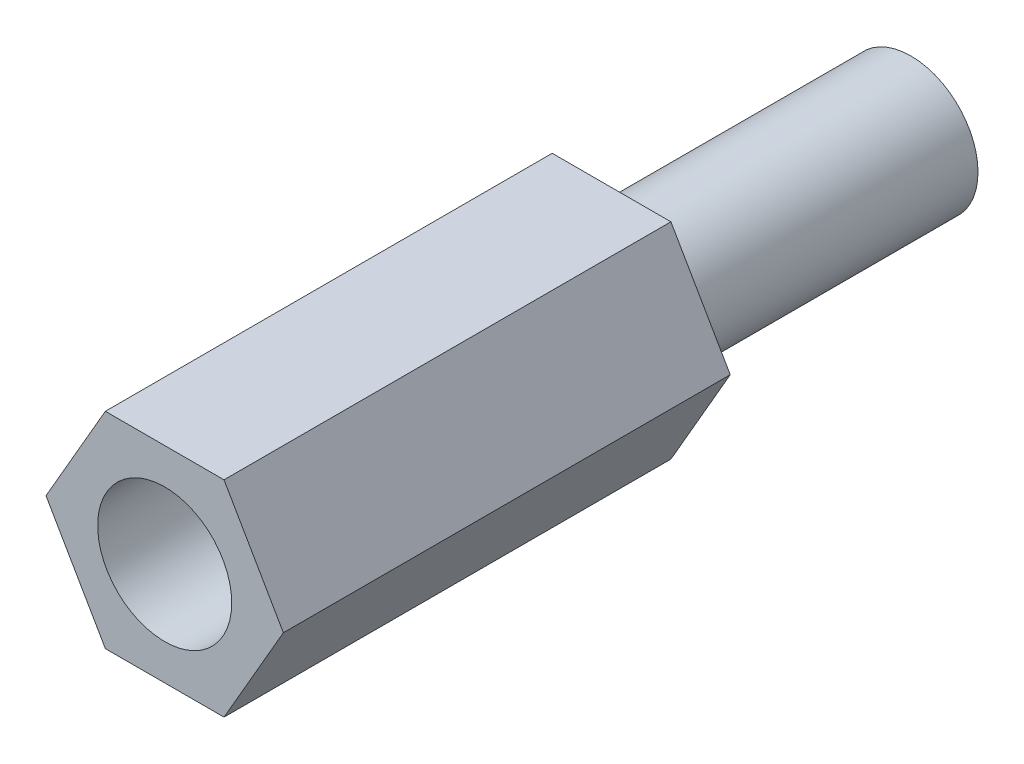
from build123d import *

# Parameters (mm, degrees)
SALIENTE_EXTRUIR1_DEPTH = 10
CROQUIS2_R              = 1.5
SALIENTE_EXTRUIR2_DEPTH = 6.7
CROQUIS3_R              = 1.5
CORTAR_EXTRUIR1_DEPTH   = 7


with BuildPart() as part:
    # Croquis1 → Saliente-Extruir1 (new body)
    with BuildSketch(Plane.XY):
        Polygon((2.655811238, 0), (1.327905619, 2.3), (-1.327905619, 2.3), (-2.655811238, 0), (-1.327905619, -2.3), (1.327905619, -2.3), align=None)
    extrude(amount=SALIENTE_EXTRUIR1_DEPTH)

    # Croquis2 → Saliente-Extruir2 (add)
    with BuildSketch(Plane(origin=(0, 0, 0), x_dir=(-1, 0, 0), z_dir=(0, 0, -1))):
        Circle(CROQUIS2_R)
    extrude(amount=SALIENTE_EXTRUIR2_DEPTH)

    # Croquis3 → Cortar-Extruir1 (cut)
    with BuildSketch(Plane.XY.offset(10)):
        Circle(CROQUIS3_R)
    extrude(amount=-CORTAR_EXTRUIR1_DEPTH, mode=Mode.SUBTRACT)


solid = part.part
